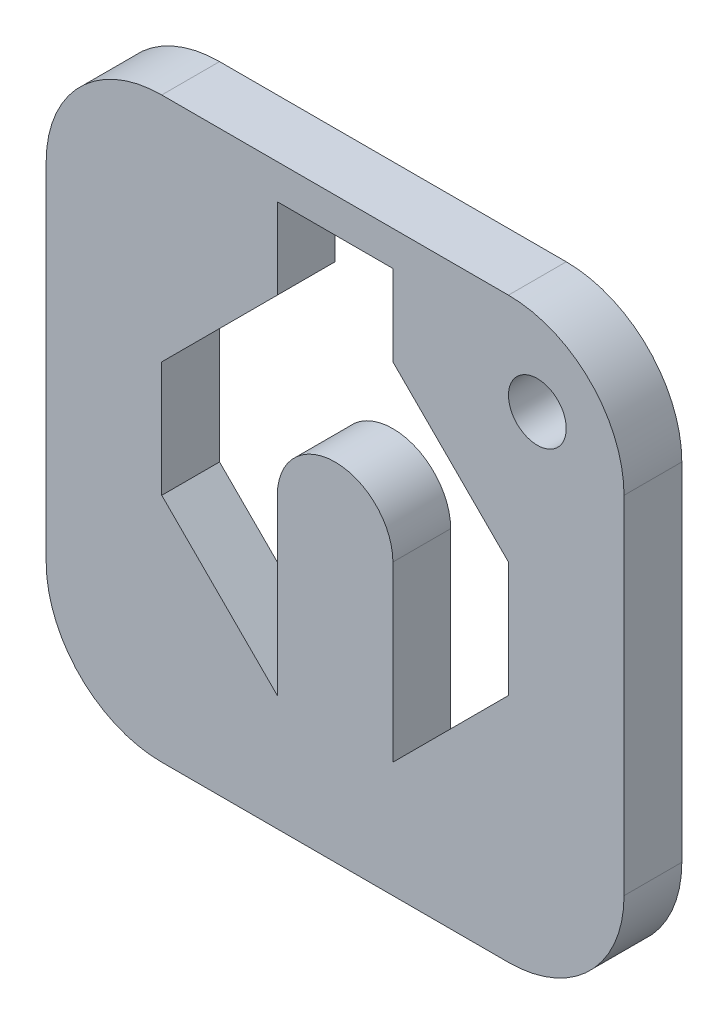
from build123d import *

# Parameters (mm, degrees)
SKETCH2_W           = 50
SKETCH2_H           = 50
BOSS_EXTRUDE1_DEPTH = 5
FILLET1_R           = 10
SKETCH3_R           = 2.5
CUT_EXTRUDE1_DEPTH  = 6


with BuildPart() as part:
    # Sketch2 → Boss-Extrude1 (new body)
    with BuildSketch(Plane.XY):
        Rectangle(SKETCH2_W, SKETCH2_H)
    extrude(amount=BOSS_EXTRUDE1_DEPTH)

    # Fillet1
    fillet1_edges = [part.edges().sort_by_distance(p)[0] for p in [
        (-25, 25, 2.5),
        (25, 25, 2.5),
        (25, -25, 2.5),
        (-25, -25, 2.5),
    ]]
    fillet(fillet1_edges, radius=FILLET1_R)

    # Sketch3 → Cut-Extrude1 (cut, through all)
    with BuildSketch(Plane.XY.offset(5)):
        with Locations((17.5, 17.5)):
            Circle(SKETCH3_R)
        with BuildLine():
            Line((-5, 0), (-5, -15))
            Line((-5, -15), (-15, -5))
            Line((-15, -5), (-15, 5))
            Line((-15, 5), (-5, 15))
            Line((-5, 15), (-5, 22))
            Line((-5, 22), (5, 22))
            Line((5, 22), (5, 15))
            Line((5, 15), (15, 5))
            Line((15, 5), (15, -5))
            Line((15, -5), (5, -15))
            Line((5, -15), (5, 0))
            ThreePointArc((5, 0), (0, 5), (-5, 0))
        make_face()
    extrude(amount=-CUT_EXTRUDE1_DEPTH, mode=Mode.SUBTRACT)


solid = part.part
